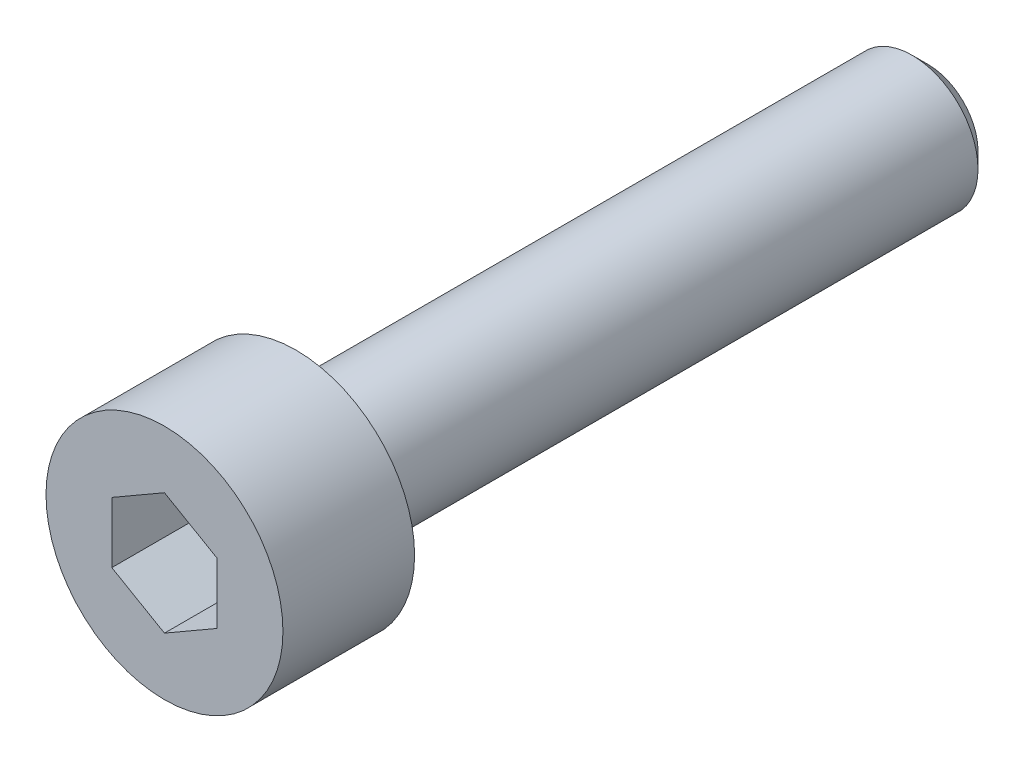
from build123d import *

# Parameters (mm, degrees)
SKETCH1_R           = 2.25
BOSS_EXTRUDE1_DEPTH = 2.5
SKETCH2_R           = 1.25
BOSS_EXTRUDE2_DEPTH = 12
CHAMFER1_SIZE       = 0.3
CUT_EXTRUDE1_DEPTH  = 2


with BuildPart() as part:
    # Sketch1 → Boss-Extrude1 (new body)
    with BuildSketch(Plane.XY):
        Circle(SKETCH1_R)
    extrude(amount=BOSS_EXTRUDE1_DEPTH)

    # Sketch2 → Boss-Extrude2 (add)
    with BuildSketch(Plane(origin=(0, 0, 0), x_dir=(-1, 0, 0), z_dir=(0, 0, -1))):
        Circle(SKETCH2_R)
    extrude(amount=BOSS_EXTRUDE2_DEPTH)

    # Chamfer1
    chamfer1_edges = [part.edges().sort_by_distance(p)[0] for p in [
        (1.25, 0, -12),
    ]]
    chamfer(chamfer1_edges, length=CHAMFER1_SIZE)

    # Sketch3 → Cut-Extrude1 (cut)
    with BuildSketch(Plane.XY.offset(2.5)):
        Polygon((0, 1.154700538), (-1, 0.577350269), (-1, -0.577350269), (0, -1.154700538), (1, -0.577350269), (1, 0.577350269), align=None)
    extrude(amount=-CUT_EXTRUDE1_DEPTH, mode=Mode.SUBTRACT)


solid = part.part
